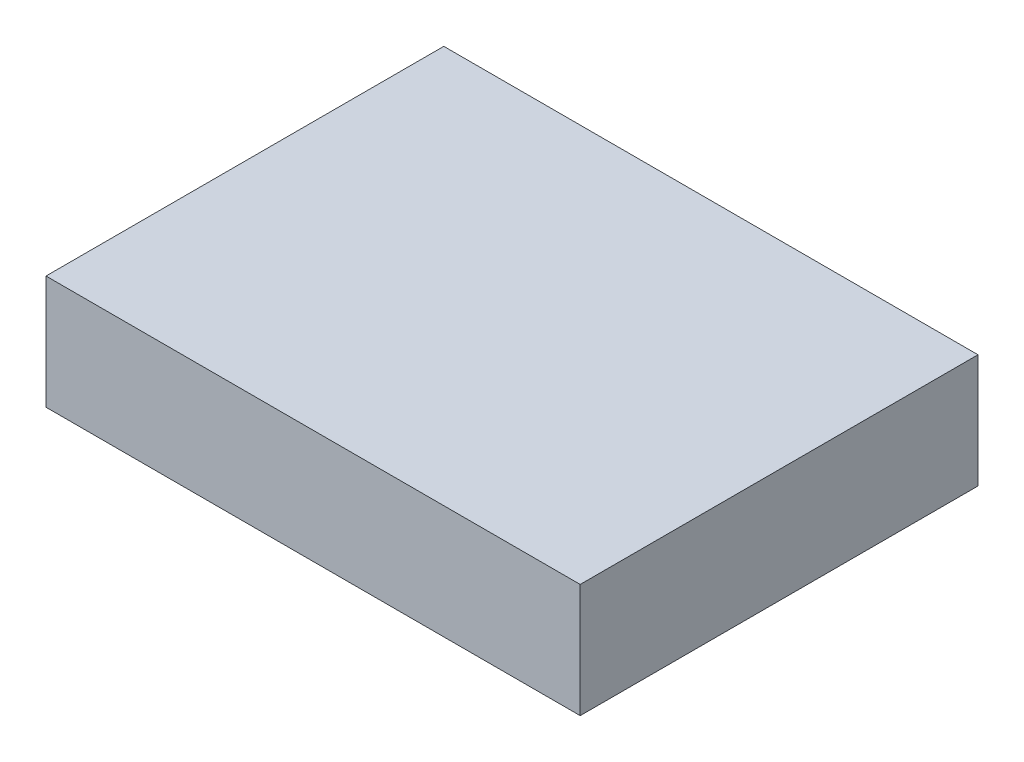
from build123d import *

# Parameters (mm, degrees)
SKETCH1_W           = 47
SKETCH1_H           = 35
BOSS_EXTRUDE1_DEPTH = 10


with BuildPart() as part:
    # Sketch1 → Boss-Extrude1 (new body)
    with BuildSketch(Plane(origin=(0, 0, 0), x_dir=(1, 0, 0), z_dir=(0, 1, 0))):
        Rectangle(SKETCH1_W, SKETCH1_H)
    extrude(amount=BOSS_EXTRUDE1_DEPTH)


solid = part.part
